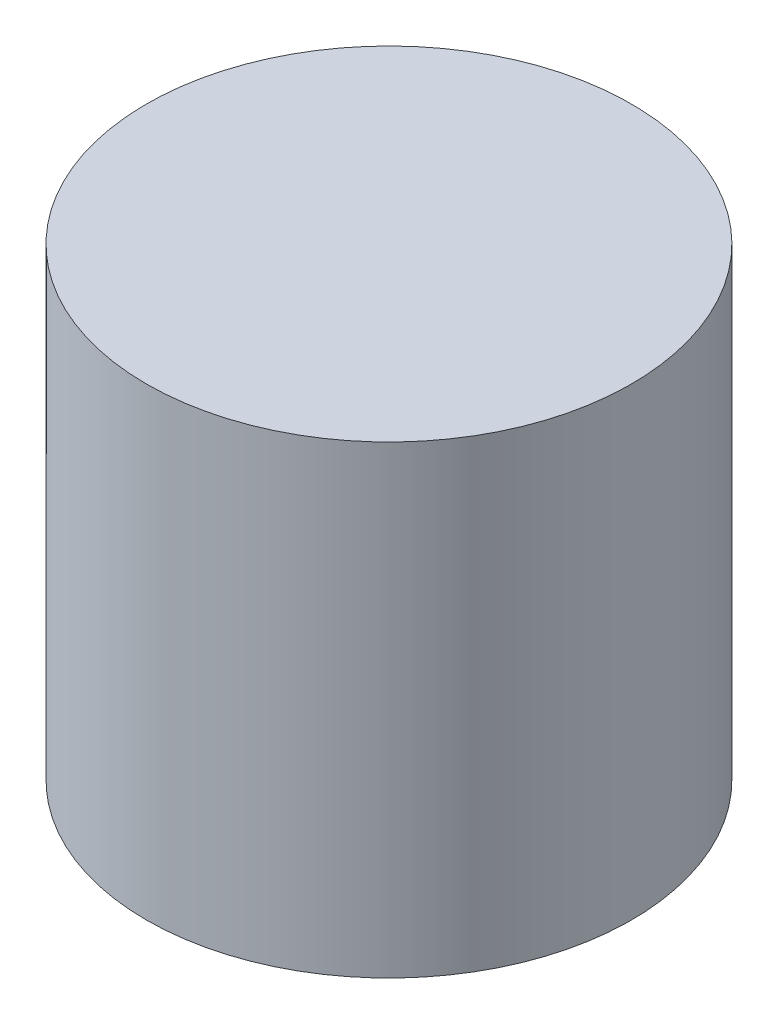
from build123d import *

# Parameters (mm, degrees)
SKETCH1_R      = 44.45
EXTRUDE1_DEPTH = 85.09


with BuildPart() as part:
    # Sketch1 → Extrude1 (new body)
    with BuildSketch(Plane(origin=(0, 0, 0), x_dir=(1, 0, 0), z_dir=(0, 1, 0))):
        with Locations(Location((0, 0, 0), (0, 0, 270))):  # turned: the seam where the file's is
            Circle(SKETCH1_R)
    extrude(amount=EXTRUDE1_DEPTH)


solid = part.part
